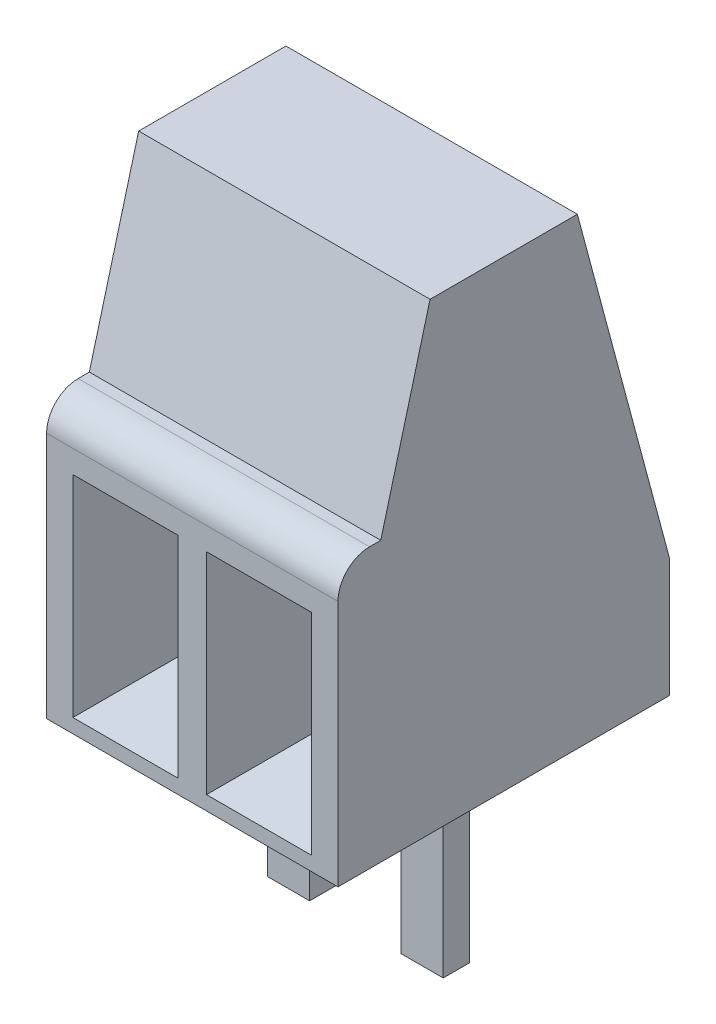
from build123d import *

# Parameters (mm, degrees)
SKETCH1_W           = 5.54
SKETCH1_H           = 6.3
BOSS_EXTRUDE1_DEPTH = 8.8
SKETCH2_W           = 0.8
SKETCH2_H           = 0.5
BOSS_EXTRUDE2_DEPTH = 3.6
CUT_EXTRUDE1_REACH  = 7.54
SKETCH4_W           = 2
SKETCH4_H           = 4
CUT_EXTRUDE2_DEPTH  = 3.15
CUT_EXTRUDE2_TAPER  = 10


with BuildPart() as part:
    # Sketch1 → Boss-Extrude1 (new body)
    with BuildSketch(Plane(origin=(0, 0, 0), x_dir=(1, 0, 0), z_dir=(0, 1, 0))):
        Rectangle(SKETCH1_W, SKETCH1_H)
    extrude(amount=BOSS_EXTRUDE1_DEPTH)

    # Sketch2 → Boss-Extrude2 (add)
    with BuildSketch(Plane(origin=(0, 0, 0), x_dir=(1, 0, 0), z_dir=(0, 1, 0))):
        with Locations((1.27, 0.2)):
            Rectangle(SKETCH2_W, SKETCH2_H)
        with Locations((-1.27, 0.2)):
            Rectangle(SKETCH2_W, SKETCH2_H)
    extrude(amount=-BOSS_EXTRUDE2_DEPTH)

    # Sketch3 → Cut-Extrude1 (cut, up to next)
    with BuildSketch(Plane(origin=(2.77, 0, 0), x_dir=(0, 0, -1), z_dir=(1, 0, 0)), mode=Mode.PRIVATE) as cut_extrude1_sk1:
        with BuildLine():
            ThreePointArc((-3.15, 4.7), (-2.974264069, 5.124264069), (-2.55, 5.3))
            Line((-2.55, 5.3), (-2.337822174, 5.3))
            Line((-2.337822174, 5.3), (-1.4, 8.8))
            Line((-1.4, 8.8), (-3.15, 8.8))
            Line((-3.15, 8.8), (-3.15, 4.7))
        make_face()
    cut_extrude1_tool1 = extrude(cut_extrude1_sk1.sketch, amount=-CUT_EXTRUDE1_REACH, mode=Mode.PRIVATE) & part.part
    add(cut_extrude1_tool1.solids().sort_by_distance((2.77, 7.227986, 2.489914))[0], mode=Mode.SUBTRACT)
    # Sketch3 → Cut-Extrude1 (cut, up to next)
    with BuildSketch(Plane(origin=(2.77, 0, 0), x_dir=(0, 0, -1), z_dir=(1, 0, 0)), mode=Mode.PRIVATE) as cut_extrude1_sk2:
        Polygon((3.15, 8.8), (1.4, 8.8), (3.15, 2.268911087), align=None)
    cut_extrude1_tool2 = extrude(cut_extrude1_sk2.sketch, amount=-CUT_EXTRUDE1_REACH, mode=Mode.PRIVATE) & part.part
    add(cut_extrude1_tool2.solids().sort_by_distance((2.77, 6.62297, -2.566667))[0], mode=Mode.SUBTRACT)

    # Sketch4 → Cut-Extrude2 (cut)
    with BuildSketch(Plane.XY.offset(3.15)):
        with Locations((-1.27, 2.268911087)):
            Rectangle(SKETCH4_W, SKETCH4_H)
        with Locations((1.27, 2.268911087)):
            Rectangle(SKETCH4_W, SKETCH4_H)
    extrude(amount=-CUT_EXTRUDE2_DEPTH, taper=CUT_EXTRUDE2_TAPER, mode=Mode.SUBTRACT)


solid = part.part
